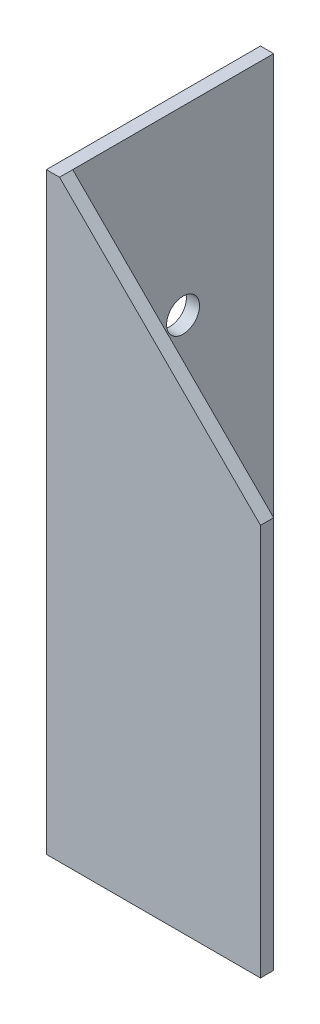
from build123d import *

# Parameters (mm, degrees)
EXTRUDE_1_DEPTH     = 180
SKETCH_6_R          = 5
CUT_EXTRUDE_1_DEPTH = 10
CUT_EXTRUDE_2_DEPTH = 10


with BuildPart() as part:
    # Эскиз1 → Вытянуть-Тонкостенный1 (new body)
    with BuildSketch(Plane(origin=(0, 0, 0), x_dir=(1, 0, 0), z_dir=(0, 1, 0))):
        Polygon((0, 65), (0, 0), (65, 0), (65, 4), (4, 4), (4, 65), align=None)
    extrude(amount=EXTRUDE_1_DEPTH)

    # Эскиз6 → Вырез-Вытянуть1 (cut)
    with BuildSketch(Plane.ZY):
        with Locations((-37.5, 25)):
            Circle(SKETCH_6_R)
        with Locations((-37.5, 75)):
            Circle(SKETCH_6_R)
        with Locations((-37.5, 125)):
            Circle(SKETCH_6_R)
    extrude(amount=-CUT_EXTRUDE_1_DEPTH, mode=Mode.SUBTRACT)

    # Эскиз7 → Вырез-Вытянуть2 (cut)
    with BuildSketch(Plane.XY):
        Polygon((4, 180), (65, 180), (65, 119), align=None)
    extrude(amount=-CUT_EXTRUDE_2_DEPTH, mode=Mode.SUBTRACT)


solid = part.part
